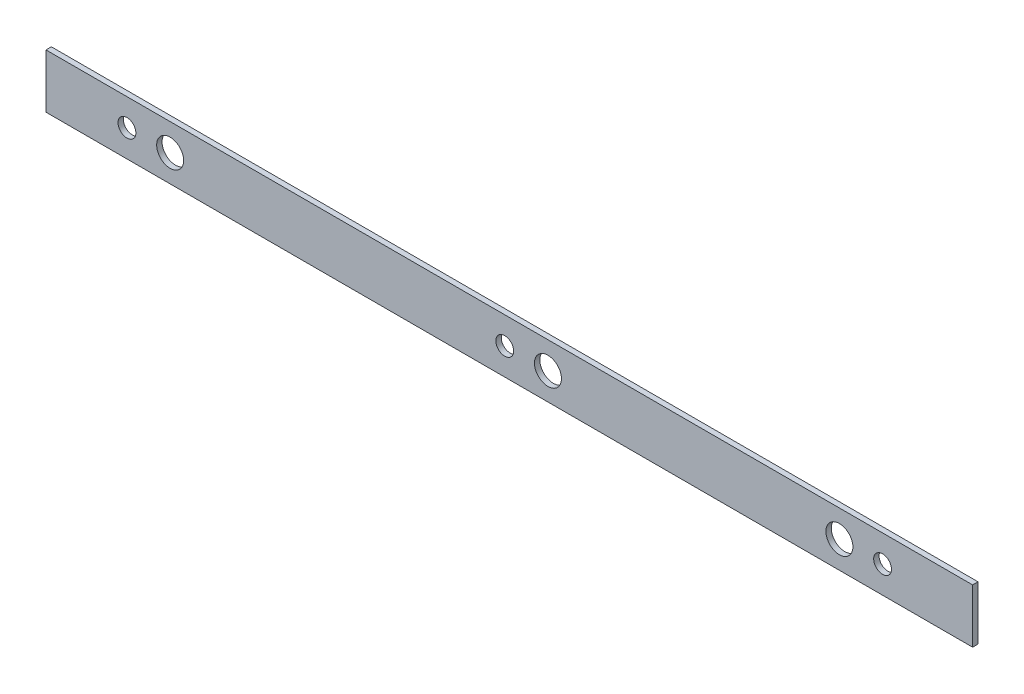
from build123d import *

# Parameters (mm, degrees)
SKETCH1_W           = 171.681197847
SKETCH1_H           = 10
SKETCH1_R           = 2.5
SKETCH1_R_2         = 1.65
BOSS_EXTRUDE1_DEPTH = 1


with BuildPart() as part:
    # Sketch1 → Boss-Extrude1 (new body)
    with BuildSketch(Plane.XY):
        with Locations((-137.259678888, 267.5)):
            Rectangle(SKETCH1_W, SKETCH1_H)
        with Locations((-200.100277812, 267.5)):
            Circle(SKETCH1_R, mode=Mode.SUBTRACT)
        with Locations((-208.100277812, 267.5)):
            Circle(SKETCH1_R_2, mode=Mode.SUBTRACT)
        with Locations((-138.100277812, 267.5)):
            Circle(SKETCH1_R_2, mode=Mode.SUBTRACT)
        with Locations((-130.100277811, 267.5)):
            Circle(SKETCH1_R, mode=Mode.SUBTRACT)
        with Locations((-76.100277812, 267.5)):
            Circle(SKETCH1_R, mode=Mode.SUBTRACT)
        with Locations((-68.100277811, 267.5)):
            Circle(SKETCH1_R_2, mode=Mode.SUBTRACT)
    extrude(amount=BOSS_EXTRUDE1_DEPTH)


solid = part.part
